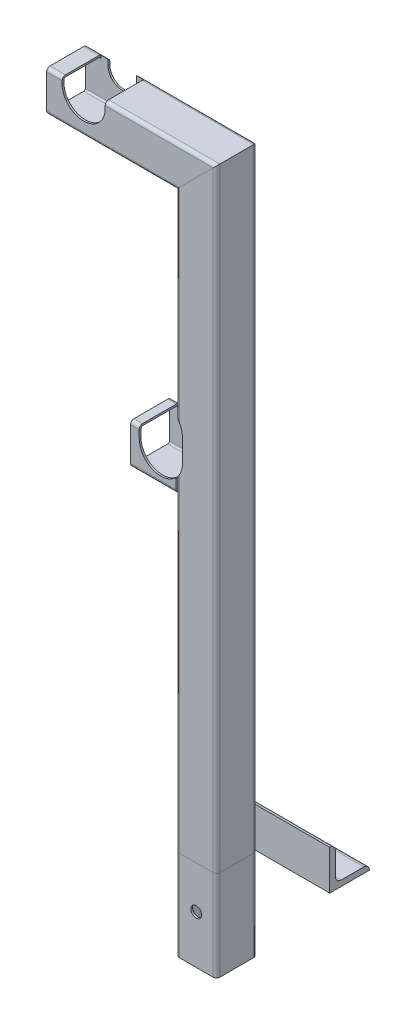
from build123d import *

# Parameters (mm, degrees)
STRUCTURAL_MEMBERMAIN_DEPTH                   = 1
STRUCTURAL_MEMBERMAIN_DEPTH_BACK              = 80
STRUCTURAL_MEMBERMAIN_2_DEPTH                 = 551.314422766
STRUCTURAL_MEMBERMAIN_3_DEPTH                 = 158.414422766
STRUCTURAL_MEMBERMAIN_4_DEPTH                 = 58.9
CUT_EXTRUDETOPRAILGUIDE_DEPTH                 = 662.71969814
CUT_EXTRUDETOPRAILGUIDE_DEPTH_BACK            = 662.71969814
STRUCTURAL_MEMBERANGLE_DEPTH                  = 100
SKETCH15_R                                    = 4.7625
CUT_EXTRUDEMOUNTINGHOLES_DEPTH                = 703.267423355
CUT_EXTRUDEENLARGERAILGUIDE_REACH             = 704.267
CUT_EXTRUDEENLARGERAILGUIDE_DIRECTION_2_DEPTH = 703.267423355
CUT_EXTRUDE1_DEPTH                            = 702.186682636
CUT_EXTRUDE2_START                            = -34.2
CUT_EXTRUDE2_DEPTH                            = 34.2
SKETCH19_R                                    = 4.7625
CUT_EXTRUDE3_DEPTH                            = 704.842144167


with BuildPart() as part:
    # Sketch11 → Structural MemberMain (new, two sides)
    with BuildSketch(Plane(origin=(361.4375, 0, 0), x_dir=(-1, 0, 0), z_dir=(0, 1, 0))) as structural_membermain_sk:
        with BuildLine():
            Line((-14.9, 17.9), (14.9, 17.9))
            ThreePointArc((14.9, 17.9), (17.021320344, 17.021320344), (17.9, 14.9))
            Line((17.9, 14.9), (17.9, -14.9))
            ThreePointArc((17.9, -14.9), (17.021320344, -17.021320344), (14.9, -17.9))
            Line((14.9, -17.9), (-14.9, -17.9))
            ThreePointArc((-14.9, -17.9), (-17.021320344, -17.021320344), (-17.9, -14.9))
            Line((-17.9, -14.9), (-17.9, 14.9))
            ThreePointArc((-17.9, 14.9), (-17.021320344, 17.021320344), (-14.9, 17.9))
        make_face()
        with BuildLine():
            Line((-14.9, 16.3), (14.9, 16.3))
            ThreePointArc((14.9, 16.3), (15.889949494, 15.889949494), (16.3, 14.9))
            Line((16.3, 14.9), (16.3, -14.9))
            ThreePointArc((16.3, -14.9), (15.889949494, -15.889949494), (14.9, -16.3))
            Line((14.9, -16.3), (-14.9, -16.3))
            ThreePointArc((-14.9, -16.3), (-15.889949494, -15.889949494), (-16.3, -14.9))
            Line((-16.3, -14.9), (-16.3, 14.9))
            ThreePointArc((-16.3, 14.9), (-15.889949494, 15.889949494), (-14.9, 16.3))
        make_face(mode=Mode.SUBTRACT)
    extrude(amount=STRUCTURAL_MEMBERMAIN_DEPTH)
    extrude(structural_membermain_sk.sketch, amount=-STRUCTURAL_MEMBERMAIN_DEPTH_BACK)

    # Structural MemberMain mitre 1
    split(bisect_by=Plane(origin=(361.4375, 0, 0), x_dir=(1, 0, 0), z_dir=(0, -1, 0)), keep=Keep.TOP)

    # Sketch19 → Cut-Extrude3 (cut, through all)
    with BuildSketch(Plane.XY.offset(17.9)):
        with Locations((361.4375, -37.5)):
            Circle(SKETCH19_R)
    extrude(amount=-CUT_EXTRUDE3_DEPTH, mode=Mode.SUBTRACT)


with BuildPart() as body_2:
    # Sketch11 on segment 2 (carried to segment 2) → Structural MemberMain 2 (new body)
    with BuildSketch(Plane(origin=(361.4375, -1, 0), x_dir=(-1, 0, 0), z_dir=(0, 1, 0))):
        with BuildLine():
            Line((-14.9, 17.9), (14.9, 17.9))
            ThreePointArc((14.9, 17.9), (17.021320344, 17.021320344), (17.9, 14.9))
            Line((17.9, 14.9), (17.9, -14.9))
            ThreePointArc((17.9, -14.9), (17.021320344, -17.021320344), (14.9, -17.9))
            Line((14.9, -17.9), (-14.9, -17.9))
            ThreePointArc((-14.9, -17.9), (-17.021320344, -17.021320344), (-17.9, -14.9))
            Line((-17.9, -14.9), (-17.9, 14.9))
            ThreePointArc((-17.9, 14.9), (-17.021320344, 17.021320344), (-14.9, 17.9))
        make_face()
        with BuildLine():
            Line((-14.9, 16.3), (14.9, 16.3))
            ThreePointArc((14.9, 16.3), (15.889949494, 15.889949494), (16.3, 14.9))
            Line((16.3, 14.9), (16.3, -14.9))
            ThreePointArc((16.3, -14.9), (15.889949494, -15.889949494), (14.9, -16.3))
            Line((14.9, -16.3), (-14.9, -16.3))
            ThreePointArc((-14.9, -16.3), (-15.889949494, -15.889949494), (-16.3, -14.9))
            Line((-16.3, -14.9), (-16.3, 14.9))
            ThreePointArc((-16.3, 14.9), (-15.889949494, 15.889949494), (-14.9, 16.3))
        make_face(mode=Mode.SUBTRACT)
    extrude(amount=STRUCTURAL_MEMBERMAIN_2_DEPTH)

    # Structural MemberMain 2 mitre 1
    split(bisect_by=Plane(origin=(361.4375, 0, 0), x_dir=(-1, 0, 0), z_dir=(0, 1, 0)), keep=Keep.TOP)

    # Structural MemberMain 2 mitre 2
    split(bisect_by=Plane(origin=(361.4375, 524, 0), x_dir=(0.707106781, 0.707106781, 0), z_dir=(0.707106781, -0.707106781, 0)), keep=Keep.TOP)


with BuildPart() as body_3:
    # Sketch11 on segment 3 (carried to segment 3) → Structural MemberMain 3 (new body)
    with BuildSketch(Plane(origin=(387.751922766, 524, 0), x_dir=(0, -1, 0), z_dir=(-1, 0, 0))):
        with BuildLine():
            Line((-14.9, 17.9), (14.9, 17.9))
            ThreePointArc((14.9, 17.9), (17.021320344, 17.021320344), (17.9, 14.9))
            Line((17.9, 14.9), (17.9, -14.9))
            ThreePointArc((17.9, -14.9), (17.021320344, -17.021320344), (14.9, -17.9))
            Line((14.9, -17.9), (-14.9, -17.9))
            ThreePointArc((-14.9, -17.9), (-17.021320344, -17.021320344), (-17.9, -14.9))
            Line((-17.9, -14.9), (-17.9, 14.9))
            ThreePointArc((-17.9, 14.9), (-17.021320344, 17.021320344), (-14.9, 17.9))
        make_face()
        with BuildLine():
            Line((-14.9, 16.3), (14.9, 16.3))
            ThreePointArc((14.9, 16.3), (15.889949494, 15.889949494), (16.3, 14.9))
            Line((16.3, 14.9), (16.3, -14.9))
            ThreePointArc((16.3, -14.9), (15.889949494, -15.889949494), (14.9, -16.3))
            Line((14.9, -16.3), (-14.9, -16.3))
            ThreePointArc((-14.9, -16.3), (-15.889949494, -15.889949494), (-16.3, -14.9))
            Line((-16.3, -14.9), (-16.3, 14.9))
            ThreePointArc((-16.3, 14.9), (-15.889949494, 15.889949494), (-14.9, 16.3))
        make_face(mode=Mode.SUBTRACT)
    extrude(amount=STRUCTURAL_MEMBERMAIN_3_DEPTH)

    # Structural MemberMain 3 mitre 1
    split(bisect_by=Plane(origin=(361.4375, 524, 0), x_dir=(-0.707106781, -0.707106781, 0), z_dir=(-0.707106781, 0.707106781, 0)), keep=Keep.TOP)

    # Sketch12 → Cut-ExtrudeTopRailGuide (cut, two sides)
    with BuildSketch(Plane.XY) as cut_extrudetoprailguide_sk:
        with BuildLine():
            Line((249.3, 536.7), (249.3, 547.1))
            ThreePointArc((249.3, 547.1), (262, 559.8), (274.7, 547.1))
            Line((274.7, 547.1), (274.7, 536.7))
            ThreePointArc((274.7, 536.7), (262, 524), (249.3, 536.7))
        make_face()
    extrude(amount=CUT_EXTRUDETOPRAILGUIDE_DEPTH, mode=Mode.SUBTRACT)
    extrude(cut_extrudetoprailguide_sk.sketch, amount=-CUT_EXTRUDETOPRAILGUIDE_DEPTH_BACK, mode=Mode.SUBTRACT)

    # Cut-ExtrudeEnlargeRailGuide: up to this face of the body (flat: up to its plane)
    cut_extrudeenlargerailguide_end = Plane(body_3.part.faces().sort_by_distance((298.537789585, 523.884806009, -16.3))[0])
    # Sketch16 → Cut-ExtrudeEnlargeRailGuide (cut, up to the picked face)
    with BuildSketch(Plane.XY, mode=Mode.PRIVATE) as cut_extrudeenlargerailguide_sk1:
        with BuildLine():
            Line((281.05, 536.7), (281.05, 547.1))
            ThreePointArc((281.05, 547.1), (262, 566.15), (242.95, 547.1))
            Line((242.95, 547.1), (242.95, 536.7))
            ThreePointArc((242.95, 536.7), (262, 517.65), (281.05, 536.7))
        make_face()
    cut_extrudeenlargerailguide_tool1 = split(extrude(cut_extrudeenlargerailguide_sk1.sketch, amount=-CUT_EXTRUDEENLARGERAILGUIDE_REACH, mode=Mode.PRIVATE), bisect_by=cut_extrudeenlargerailguide_end, keep=Keep.BOTH, mode=Mode.PRIVATE)
    add(cut_extrudeenlargerailguide_tool1.solids().sort_by(Axis((262, 541.9, 0), (0, 0, -1)))[0], mode=Mode.SUBTRACT)

    # Sketch16 → Cut-ExtrudeEnlargeRailGuide direction 2 (cut)
    with BuildSketch(Plane.XY):
        with BuildLine():
            Line((281.05, 536.7), (281.05, 547.1))
            ThreePointArc((281.05, 547.1), (262, 566.15), (242.95, 547.1))
            Line((242.95, 547.1), (242.95, 536.7))
            ThreePointArc((242.95, 536.7), (262, 517.65), (281.05, 536.7))
        make_face()
    extrude(amount=CUT_EXTRUDEENLARGERAILGUIDE_DIRECTION_2_DEPTH, mode=Mode.SUBTRACT)


with BuildPart() as body_4:
    # Sketch11 on segment 4 (carried to segment 4) → Structural MemberMain 4 (new body)
    with BuildSketch(Plane(origin=(303.5375, 291.4, 0), x_dir=(0, 1, 0), z_dir=(1, 0, 0))):
        with BuildLine():
            Line((-14.9, 17.9), (14.9, 17.9))
            ThreePointArc((14.9, 17.9), (17.021320344, 17.021320344), (17.9, 14.9))
            Line((17.9, 14.9), (17.9, -14.9))
            ThreePointArc((17.9, -14.9), (17.021320344, -17.021320344), (14.9, -17.9))
            Line((14.9, -17.9), (-14.9, -17.9))
            ThreePointArc((-14.9, -17.9), (-17.021320344, -17.021320344), (-17.9, -14.9))
            Line((-17.9, -14.9), (-17.9, 14.9))
            ThreePointArc((-17.9, 14.9), (-17.021320344, 17.021320344), (-14.9, 17.9))
        make_face()
        with BuildLine():
            Line((-14.9, 16.3), (14.9, 16.3))
            ThreePointArc((14.9, 16.3), (15.889949494, 15.889949494), (16.3, 14.9))
            Line((16.3, 14.9), (16.3, -14.9))
            ThreePointArc((16.3, -14.9), (15.889949494, -15.889949494), (14.9, -16.3))
            Line((14.9, -16.3), (-14.9, -16.3))
            ThreePointArc((-14.9, -16.3), (-15.889949494, -15.889949494), (-16.3, -14.9))
            Line((-16.3, -14.9), (-16.3, 14.9))
            ThreePointArc((-16.3, 14.9), (-15.889949494, 15.889949494), (-14.9, 16.3))
        make_face(mode=Mode.SUBTRACT)
    extrude(amount=STRUCTURAL_MEMBERMAIN_4_DEPTH)

    # Structural MemberMain 4 mitre 1
    split(bisect_by=Plane(origin=(343.5375, 291.4, 0), x_dir=(0, -1, 0), z_dir=(-1, 0, 0)), keep=Keep.TOP)

    # Sketch17 → Cut-Extrude1 (cut, through all)
    with BuildSketch(Plane.XY.offset(-17.9)):
        with BuildLine():
            Line((317.5, 304.1), (317.5, 314.5))
            ThreePointArc((317.5, 314.5), (330.2, 327.2), (342.9, 314.5))
            Line((342.9, 314.5), (342.9, 304.1))
            ThreePointArc((342.9, 304.1), (330.2, 291.4), (317.5, 304.1))
        make_face()
    extrude(amount=CUT_EXTRUDE1_DEPTH, mode=Mode.SUBTRACT)


with BuildPart() as body_5:
    # Sketch14 → Structural MemberAngle (new body)
    with BuildSketch(Plane(origin=(343.5375, 0, -17.9), x_dir=(0, 0, -1), z_dir=(1, 0, 0))):
        with BuildLine():
            Line((0, 0), (0, 35))
            ThreePointArc((0, 35), (3.535533906, 33.535533906), (5, 30))
            Line((5, 30), (5, 10))
            ThreePointArc((5, 10), (6.464466094, 6.464466094), (10, 5))
            Line((10, 5), (30, 5))
            ThreePointArc((30, 5), (33.535533906, 3.535533906), (35, 0))
            Line((35, 0), (0, 0))
        make_face()
    extrude(amount=STRUCTURAL_MEMBERANGLE_DEPTH)

    # Sketch15 → Cut-ExtrudeMountingHoles (cut, through all)
    with BuildSketch(Plane(origin=(0, 0, 0), x_dir=(1, 0, 0), z_dir=(0, 1, 0))):
        with Locations(Location((375, 37.9, 0), (0, 0, 90))):
            Circle(SKETCH15_R)
        with Locations(Location((410, 37.9, 0), (0, 0, 90))):
            Circle(SKETCH15_R)
    extrude(amount=CUT_EXTRUDEMOUNTINGHOLES_DEPTH, mode=Mode.SUBTRACT)


with BuildPart() as cut_extrude2_tool:
    # Sketch18 → Cut-Extrude2 (new body)
    with BuildSketch(Plane.XY.offset(17.9).offset(CUT_EXTRUDE2_START)):
        with BuildLine():
            Line((349.3, 319.3), (349.3, 299.3))
            ThreePointArc((349.3, 299.3), (330.2, 280.2), (311.1, 299.3))
            Line((311.1, 299.3), (311.1, 319.3))
            ThreePointArc((311.1, 319.3), (330.2, 338.4), (349.3, 319.3))
        make_face()
    extrude(amount=CUT_EXTRUDE2_DEPTH)


with BuildPart() as body_2_1:
    add(body_2.part)

    # Cut-Extrude2: cut by cut_extrude2_tool
    add(cut_extrude2_tool.part, mode=Mode.SUBTRACT)


with BuildPart() as body_4_1:
    add(body_4.part)

    # Cut-Extrude2: cut by cut_extrude2_tool
    add(cut_extrude2_tool.part, mode=Mode.SUBTRACT)


solid = Compound([part.part, body_3.part, body_5.part, body_2_1.part, body_4_1.part])
